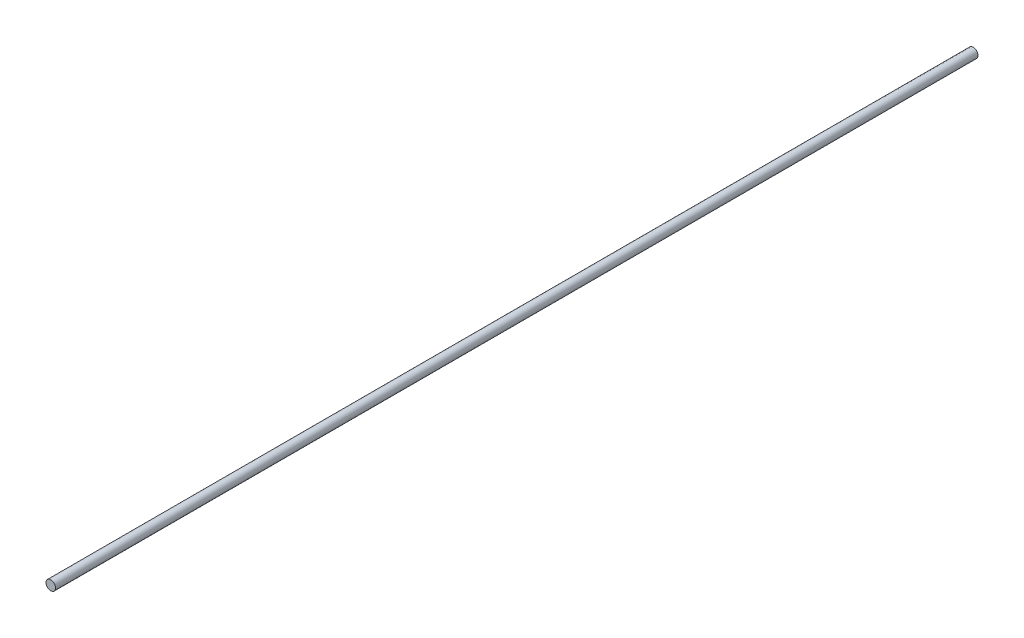
from build123d import *

# Parameters (mm, degrees)
SKETCH1_R           = 3.175
BOSS_EXTRUDE1_DEPTH = 307.34


with BuildPart() as part:
    # Sketch1 → Boss-Extrude1 (new body, symmetric)
    with BuildSketch(Plane.XY):
        Circle(SKETCH1_R)
    extrude(amount=BOSS_EXTRUDE1_DEPTH, both=True)


solid = part.part
